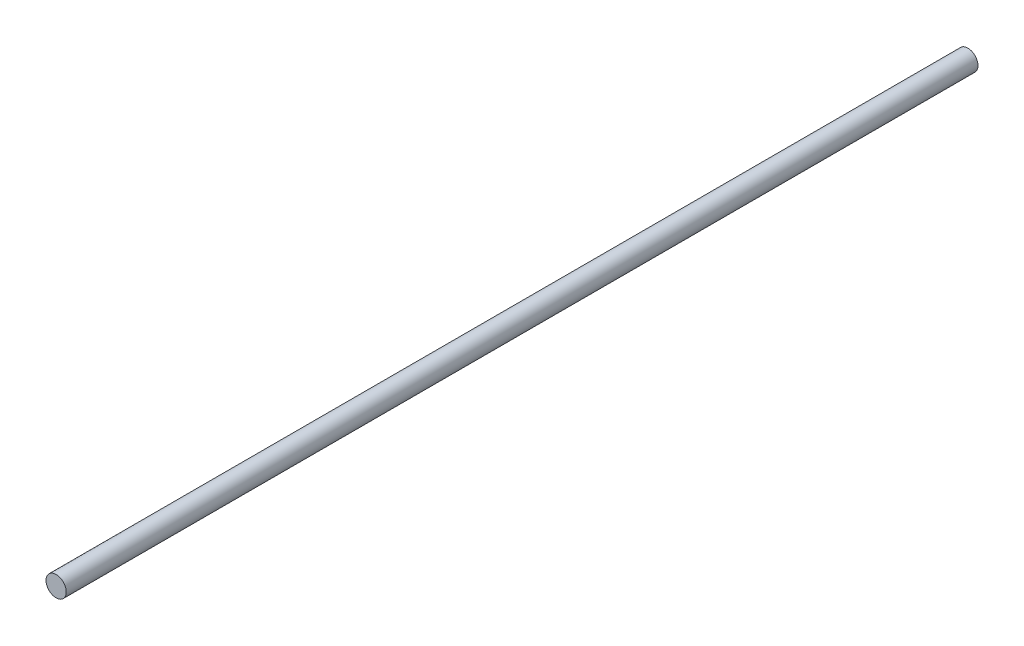
from build123d import *

# Parameters (mm, degrees)
ESQUISSE1_R = 4


with BuildPart() as part:
    # Balayage1: sweep along a path in Esquisse2
    with BuildLine(Plane(origin=(0, 0, 0), x_dir=(1, 0, 0), z_dir=(0, 1, 0))) as balayage1_path:
        Line((0, 0), (0, 360))
    # Esquisse1 → Balayage1 (sweep)
    with BuildSketch(Plane.XY):
        Circle(ESQUISSE1_R)
    sweep(path=balayage1_path.line)


solid = part.part
